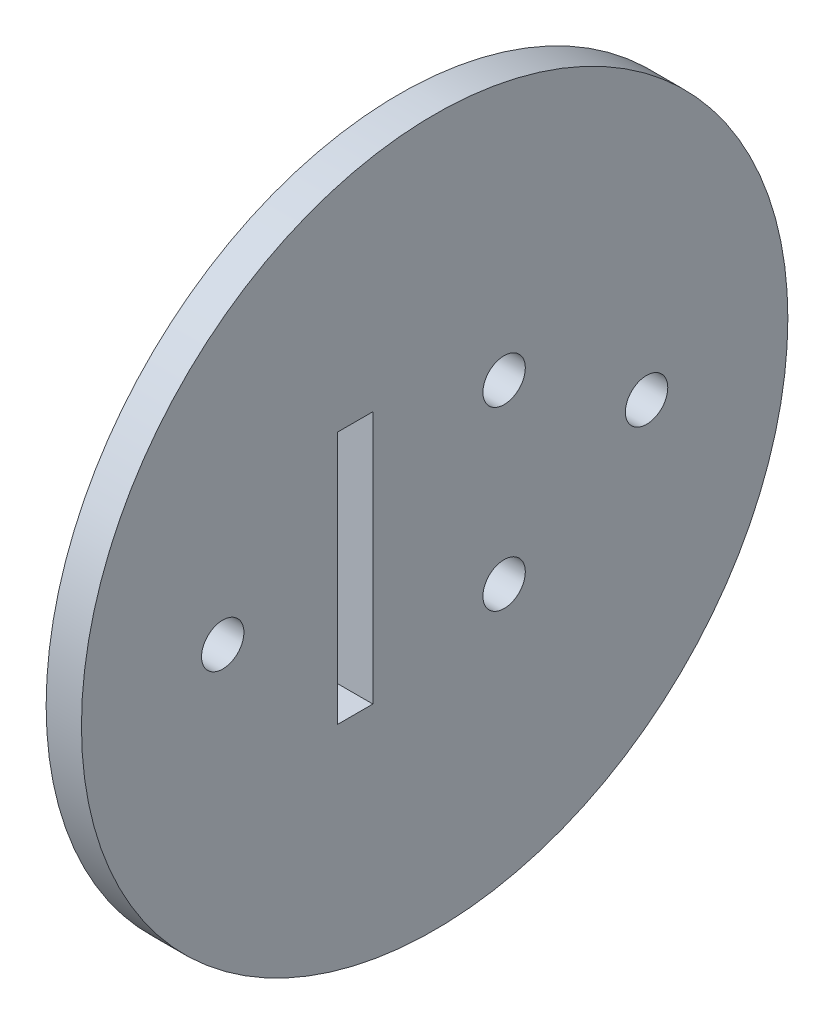
from build123d import *

# Parameters (mm, degrees)
SKETCH1_R           = 30
BOSS_EXTRUDE1_DEPTH = 3
SKETCH2_R           = 1.8
SKETCH2_W           = 3
SKETCH2_H           = 21.5
CUT_EXTRUDE1_DEPTH  = 3


with BuildPart() as part:
    # Sketch1 → Boss-Extrude1 (new body)
    with BuildSketch(Plane(origin=(0, 0, 0), x_dir=(0, 0, -1), z_dir=(1, 0, 0))):
        Circle(SKETCH1_R)
    extrude(amount=BOSS_EXTRUDE1_DEPTH)

    # Sketch2 → Cut-Extrude1 (cut)
    with BuildSketch(Plane(origin=(3, 0, 0), x_dir=(0, 0, -1), z_dir=(1, 0, 0))):
        with Locations((18, 0)):
            Circle(SKETCH2_R)
        with Locations((-18, 0)):
            Circle(SKETCH2_R)
        with Locations((5.9, 7.5)):
            Circle(SKETCH2_R)
        with Locations((5.9, -7.5)):
            Circle(SKETCH2_R)
        with Locations((-6.75, 0)):
            Rectangle(SKETCH2_W, SKETCH2_H)
    extrude(amount=-CUT_EXTRUDE1_DEPTH, mode=Mode.SUBTRACT)


solid = part.part
